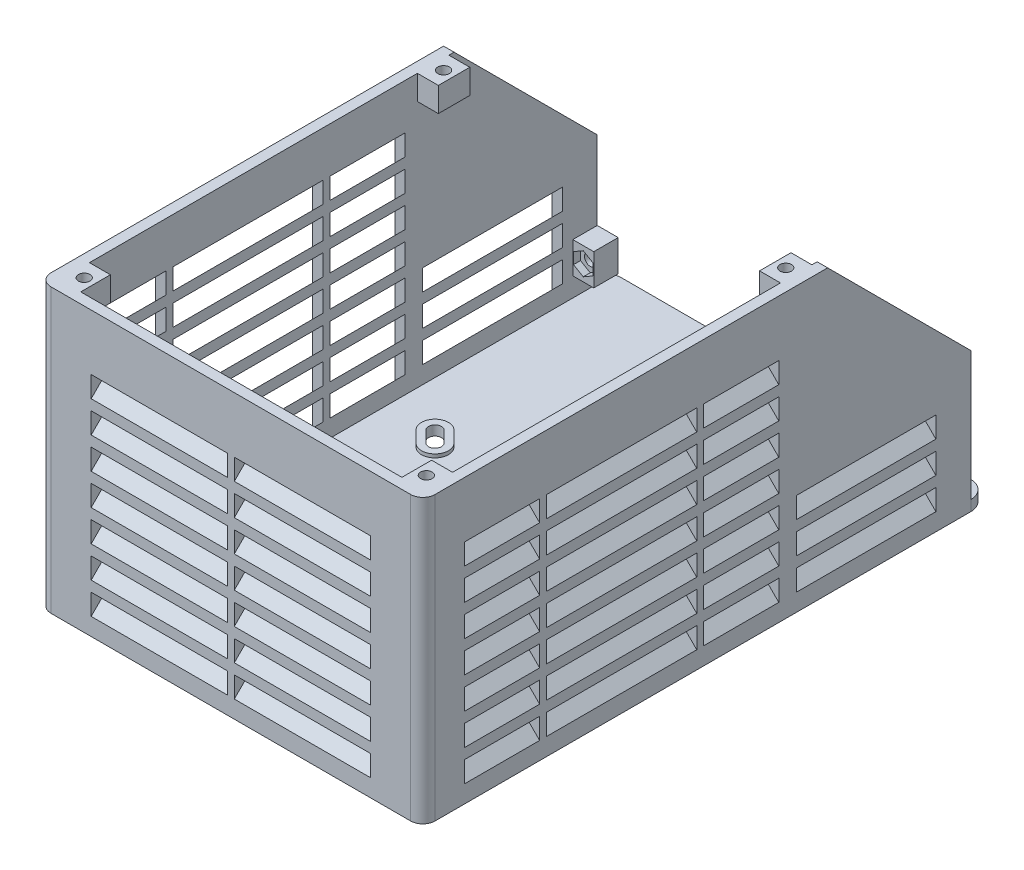
from build123d import *

# Parameters (mm, degrees)
SKETCH_2_W          = 110
SKETCH_2_H          = 161.953318806
SKETCH_2_R          = 1.75
EXTRUDE_1_DEPTH     = 3
FILLET_1_R          = 3.5
FILLET_2_R          = 5
EXTRUDE_2_DEPTH     = 78
CUT_EXTRUDE_1_DEPTH = 111
CUT_EXTRUDE_8_DEPTH = 82
CUT_EXTRUDE_9_DEPTH = 1.2
CUT_EXTRUDE_2_DEPTH = 90
CUT_EXTRUDE_3_DEPTH = 40
CUT_EXTRUDE_7_DEPTH = 40
EXTRUDE_START       = 2
SKETCH_7_W          = 3
SKETCH_7_H          = 2
SKETCH_7_W_2        = 2
SKETCH_7_H_2        = 3
EXTRUDE_3_DEPTH     = 63
EXTRUDE_7_DEPTH     = 1
SKETCH_10_R         = 5.5
CUT_EXTRUDE_4_DEPTH = 0.8
SKETCH_11_W         = 6
SKETCH_11_H         = 9
SKETCH_11_R         = 1.65
EXTRUDE_5_DEPTH     = 7
CUT_EXTRUDE_5_DEPTH = 2
SKETCH_13_W         = 6
SKETCH_13_H         = 9
SKETCH_13_R         = 1.65
EXTRUDE_6_DEPTH     = 7
CUT_EXTRUDE_6_DEPTH = 2


with BuildPart() as part:
    # 草图2 → 凸台-拉伸1 (new body)
    with BuildSketch(Plane(origin=(0, 0, 0), x_dir=(1, 0, 0), z_dir=(0, 1, 0))):
        Rectangle(SKETCH_2_W, SKETCH_2_H)
        with Locations((-37.476659403, 14.976659403)):
            Circle(SKETCH_2_R, mode=Mode.SUBTRACT)
        with Locations((-37.476659403, -59.976659403)):
            Circle(SKETCH_2_R, mode=Mode.SUBTRACT)
        with Locations((37.476659403, -59.976659403)):
            Circle(SKETCH_2_R, mode=Mode.SUBTRACT)
        with Locations((37.476659403, 14.976659403)):
            Circle(SKETCH_2_R, mode=Mode.SUBTRACT)
    extrude(amount=EXTRUDE_1_DEPTH)

    # 圆角1
    fillet_1_edges = [part.edges().sort_by_distance(p)[0] for p in [
        (55, 1.5, 80.976659403),
        (-55, 1.5, 80.976659403),
    ]]
    fillet(fillet_1_edges, radius=FILLET_1_R)

    # 圆角2
    fillet_2_edges = [part.edges().sort_by_distance(p)[0] for p in [
        (-55, 1.5, -80.976659403),
        (55, 1.5, -80.976659403),
    ]]
    fillet(fillet_2_edges, radius=FILLET_2_R)

    # 草图3 → 凸台-拉伸2 (add)
    with BuildSketch(Plane(origin=(0, 3, 0), x_dir=(1, 0, 0), z_dir=(0, 1, 0))):
        with BuildLine():
            Line((-52, 75.976659403), (-52, -77.476659403))
            ThreePointArc((-52, -77.476659403), (-51.853553391, -77.830212793), (-51.5, -77.976659403))
            Line((-51.5, -77.976659403), (51.5, -77.976659403))
            ThreePointArc((51.5, -77.976659403), (51.853553391, -77.830212793), (52, -77.476659403))
            Line((52, -77.476659403), (52, 75.976659403))
            Line((52, 75.976659403), (55, 75.976659403))
            Line((55, 75.976659403), (55, -77.476659403))
            ThreePointArc((55, -77.476659403), (53.974873734, -79.951533137), (51.5, -80.976659403))
            Line((51.5, -80.976659403), (-51.5, -80.976659403))
            ThreePointArc((-51.5, -80.976659403), (-53.974873734, -79.951533137), (-55, -77.476659403))
            Line((-55, -77.476659403), (-55, 75.976659403))
            Line((-55, 75.976659403), (-52, 75.976659403))
        make_face()
    extrude(amount=EXTRUDE_2_DEPTH)

    # 草图4 → 切除-拉伸1 (cut, through all)
    with BuildSketch(Plane(origin=(55, 0, 0), x_dir=(0, 0, -1), z_dir=(1, 0, 0))):
        Polygon((75.976659403, 81), (75.976659403, 39.987806691), (34.964466094, 81), align=None)
    extrude(amount=-CUT_EXTRUDE_1_DEPTH, mode=Mode.SUBTRACT)

    # 草图16 → 切除-拉伸8 (cut, through all)
    with BuildSketch(Plane.XZ):
        with BuildLine():
            Line((-36.663486605, 61.779781695), (-33.481506089, 58.59780118))
            ThreePointArc((-33.481506089, 58.59780118), (-33.481506089, 55.981506089), (-36.09780118, 55.981506089))
            Line((-36.09780118, 55.981506089), (-39.279781695, 59.163486605))
            ThreePointArc((-39.279781695, 59.163486605), (-39.279781695, 61.779781695), (-36.663486605, 61.779781695))
        make_face()
        with BuildLine():
            Line((39.279781695, 59.163486605), (36.09780118, 55.981506089))
            ThreePointArc((36.09780118, 55.981506089), (33.481506089, 55.981506089), (33.481506089, 58.59780118))
            Line((33.481506089, 58.59780118), (36.663486605, 61.779781695))
            ThreePointArc((36.663486605, 61.779781695), (39.279781695, 61.779781695), (39.279781695, 59.163486605))
        make_face()
        with BuildLine():
            Line((36.663486605, -16.779781695), (33.481506089, -13.59780118))
            ThreePointArc((33.481506089, -13.59780118), (33.481506089, -10.981506089), (36.09780118, -10.981506089))
            Line((36.09780118, -10.981506089), (39.279781695, -14.163486605))
            ThreePointArc((39.279781695, -14.163486605), (39.279781695, -16.779781695), (36.663486605, -16.779781695))
        make_face()
        with BuildLine():
            Line((-39.279781695, -14.163486605), (-36.09780118, -10.981506089))
            ThreePointArc((-36.09780118, -10.981506089), (-33.481506089, -10.981506089), (-33.481506089, -13.59780118))
            Line((-33.481506089, -13.59780118), (-36.663486605, -16.779781695))
            ThreePointArc((-36.663486605, -16.779781695), (-39.279781695, -16.779781695), (-39.279781695, -14.163486605))
        make_face()
    extrude(amount=-CUT_EXTRUDE_8_DEPTH, mode=Mode.SUBTRACT)

    # 草图17 → 切除-拉伸9 (cut)
    with BuildSketch(Plane.XZ):
        with BuildLine():
            Line((32.279424561, -14.799882708), (35.461405077, -17.981863223))
            ThreePointArc((35.461405077, -17.981863223), (40.481863223, -17.981863223), (40.481863223, -12.961405077))
            Line((40.481863223, -12.961405077), (37.299882708, -9.779424561))
            ThreePointArc((37.299882708, -9.779424561), (32.279424561, -9.779424561), (32.279424561, -14.799882708))
        make_face()
        with BuildLine():
            Line((33.481506089, -13.59780118), (36.663486605, -16.779781695))
            ThreePointArc((36.663486605, -16.779781695), (39.279781695, -16.779781695), (39.279781695, -14.163486605))
            Line((39.279781695, -14.163486605), (36.09780118, -10.981506089))
            ThreePointArc((36.09780118, -10.981506089), (33.481506089, -10.981506089), (33.481506089, -13.59780118))
        make_face(mode=Mode.SUBTRACT)
        with BuildLine():
            Line((-37.299882708, -9.779424561), (-40.481863223, -12.961405077))
            ThreePointArc((-40.481863223, -12.961405077), (-40.481863223, -17.981863223), (-35.461405077, -17.981863223))
            Line((-35.461405077, -17.981863223), (-32.279424561, -14.799882708))
            ThreePointArc((-32.279424561, -14.799882708), (-32.279424561, -9.779424561), (-37.299882708, -9.779424561))
        make_face()
        with BuildLine():
            Line((-36.09780118, -10.981506089), (-39.279781695, -14.163486605))
            ThreePointArc((-39.279781695, -14.163486605), (-39.279781695, -16.779781695), (-36.663486605, -16.779781695))
            Line((-36.663486605, -16.779781695), (-33.481506089, -13.59780118))
            ThreePointArc((-33.481506089, -13.59780118), (-33.481506089, -10.981506089), (-36.09780118, -10.981506089))
        make_face(mode=Mode.SUBTRACT)
        with BuildLine():
            Line((37.299882708, 54.779424561), (40.481863223, 57.961405077))
            ThreePointArc((40.481863223, 57.961405077), (40.481863223, 62.981863223), (35.461405077, 62.981863223))
            Line((35.461405077, 62.981863223), (32.279424561, 59.799882708))
            ThreePointArc((32.279424561, 59.799882708), (32.279424561, 54.779424561), (37.299882708, 54.779424561))
        make_face()
        with BuildLine():
            Line((36.09780118, 55.981506089), (39.279781695, 59.163486605))
            ThreePointArc((39.279781695, 59.163486605), (39.279781695, 61.779781695), (36.663486605, 61.779781695))
            Line((36.663486605, 61.779781695), (33.481506089, 58.59780118))
            ThreePointArc((33.481506089, 58.59780118), (33.481506089, 55.981506089), (36.09780118, 55.981506089))
        make_face(mode=Mode.SUBTRACT)
        with BuildLine():
            Line((-40.481863223, 57.961405077), (-37.299882708, 54.779424561))
            ThreePointArc((-37.299882708, 54.779424561), (-32.279424561, 54.779424561), (-32.279424561, 59.799882708))
            Line((-32.279424561, 59.799882708), (-35.461405077, 62.981863223))
            ThreePointArc((-35.461405077, 62.981863223), (-40.481863223, 62.981863223), (-40.481863223, 57.961405077))
        make_face()
        with BuildLine():
            Line((-39.279781695, 59.163486605), (-36.09780118, 55.981506089))
            ThreePointArc((-36.09780118, 55.981506089), (-33.481506089, 55.981506089), (-33.481506089, 58.59780118))
            Line((-33.481506089, 58.59780118), (-36.663486605, 61.779781695))
            ThreePointArc((-36.663486605, 61.779781695), (-39.279781695, 61.779781695), (-39.279781695, 59.163486605))
        make_face(mode=Mode.SUBTRACT)
    extrude(amount=-CUT_EXTRUDE_9_DEPTH, mode=Mode.SUBTRACT)

    # 草图6 → 切除-拉伸2 (cut)
    with BuildSketch(Plane(origin=(0, 0, -20.976659403), x_dir=(-1, 0, 0), z_dir=(0, 0, -1))):
        Polygon((-52, 68), (-55, 65), (-55, 59), (-52, 62), align=None)
        Polygon((-52, 59), (-55, 56), (-55, 50), (-52, 53), align=None)
        Polygon((-52, 50), (-55, 47), (-55, 41), (-52, 44), align=None)
        Polygon((-52, 41), (-55, 38), (-55, 32), (-52, 35), align=None)
        Polygon((-52, 32), (-55, 29), (-55, 23), (-52, 26), align=None)
        Polygon((-52, 23), (-55, 20), (-55, 14), (-52, 17), align=None)
        Polygon((-52, 14), (-55, 11), (-55, 5), (-52, 8), align=None)
        Polygon((52, 8), (55, 5), (55, 11), (52, 14), align=None)
        Polygon((52, 17), (55, 14), (55, 20), (52, 23), align=None)
        Polygon((52, 26), (55, 23), (55, 29), (52, 32), align=None)
        Polygon((52, 35), (55, 32), (55, 38), (52, 41), align=None)
        Polygon((52, 44), (55, 41), (55, 47), (52, 50), align=None)
        Polygon((52, 53), (55, 50), (55, 56), (52, 59), align=None)
        Polygon((52, 62), (55, 59), (55, 65), (52, 68), align=None)
    extrude(amount=-CUT_EXTRUDE_2_DEPTH, mode=Mode.SUBTRACT)

    # 草图8 → 切除-拉伸3 (cut, symmetric)
    with BuildSketch(Plane(origin=(0, 0, 0), x_dir=(0, 0, -1), z_dir=(1, 0, 0))):
        Polygon((-80.976659403, 65), (-77.976659403, 68), (-77.976659403, 62), (-80.976659403, 59), align=None)
        Polygon((-77.976659403, 59), (-77.976659403, 53), (-80.976659403, 50), (-80.976659403, 56), align=None)
        Polygon((-77.976659403, 50), (-77.976659403, 44), (-80.976659403, 41), (-80.976659403, 47), align=None)
        Polygon((-77.976659403, 41), (-77.976659403, 35), (-80.976659403, 32), (-80.976659403, 38), align=None)
        Polygon((-77.976659403, 32), (-77.976659403, 26), (-80.976659403, 23), (-80.976659403, 29), align=None)
        Polygon((-77.976659403, 23), (-77.976659403, 17), (-80.976659403, 14), (-80.976659403, 20), align=None)
        Polygon((-77.976659403, 14), (-77.976659403, 8), (-80.976659403, 5), (-80.976659403, 11), align=None)
    extrude(amount=CUT_EXTRUDE_3_DEPTH, both=True, mode=Mode.SUBTRACT)

    # 草图15 → 切除-拉伸7 (cut)
    with BuildSketch(Plane(origin=(0, 0, -65.976659403), x_dir=(-1, 0, 0), z_dir=(0, 0, -1))):
        Polygon((-52, 14), (-55, 11), (-55, 5), (-52, 8), align=None)
        Polygon((-55, 20), (-55, 14), (-52, 17), (-52, 23), align=None)
        Polygon((-55, 29), (-55, 23), (-52, 26), (-52, 32), align=None)
        Polygon((52, 26), (55, 23), (55, 29), (52, 32), align=None)
        Polygon((52, 17), (55, 14), (55, 20), (52, 23), align=None)
        Polygon((52, 8), (55, 5), (55, 11), (52, 14), align=None)
    extrude(amount=-CUT_EXTRUDE_7_DEPTH, mode=Mode.SUBTRACT)

    # 草图7 → 凸台-拉伸3 (add)
    with BuildSketch(Plane(origin=(0, 3, 0), x_dir=(1, 0, 0), z_dir=(0, 1, 0)).offset(EXTRUDE_START)):
        with Locations((53.5, -46.523340597)):
            Rectangle(SKETCH_7_W, SKETCH_7_H)
        with Locations((53.5, -1.523340597)):
            Rectangle(SKETCH_7_W, SKETCH_7_H)
        with Locations((-53.5, -46.523340597)):
            Rectangle(SKETCH_7_W, SKETCH_7_H)
        with Locations((-53.5, -1.523340597)):
            Rectangle(SKETCH_7_W, SKETCH_7_H)
        with Locations((0, -79.476659403)):
            Rectangle(SKETCH_7_W_2, SKETCH_7_H_2)
    extrude(amount=EXTRUDE_3_DEPTH)

    # 草图9 → 凸台-拉伸7 (add)
    with BuildSketch(Plane(origin=(0, 3, 0), x_dir=(1, 0, 0), z_dir=(0, 1, 0))):
        with BuildLine():
            Line((40.693995257, 12.749273042), (37.512014742, 9.567292527))
            ThreePointArc((37.512014742, 9.567292527), (32.067292527, 9.567292527), (32.067292527, 15.012014742))
            Line((32.067292527, 15.012014742), (35.249273042, 18.193995257))
            ThreePointArc((35.249273042, 18.193995257), (40.693995257, 18.193995257), (40.693995257, 12.749273042))
        make_face()
        with BuildLine():
            Line((39.279781695, 14.163486605), (36.09780118, 10.981506089))
            ThreePointArc((36.09780118, 10.981506089), (33.481506089, 10.981506089), (33.481506089, 13.59780118))
            Line((33.481506089, 13.59780118), (36.663486605, 16.779781695))
            ThreePointArc((36.663486605, 16.779781695), (39.279781695, 16.779781695), (39.279781695, 14.163486605))
        make_face(mode=Mode.SUBTRACT)
        with BuildLine():
            Line((-37.512014742, 9.567292527), (-40.693995257, 12.749273042))
            ThreePointArc((-40.693995257, 12.749273042), (-40.693995257, 18.193995257), (-35.249273042, 18.193995257))
            Line((-35.249273042, 18.193995257), (-32.067292527, 15.012014742))
            ThreePointArc((-32.067292527, 15.012014742), (-32.067292527, 9.567292527), (-37.512014742, 9.567292527))
        make_face()
        with BuildLine():
            Line((-36.09780118, 10.981506089), (-39.279781695, 14.163486605))
            ThreePointArc((-39.279781695, 14.163486605), (-39.279781695, 16.779781695), (-36.663486605, 16.779781695))
            Line((-36.663486605, 16.779781695), (-33.481506089, 13.59780118))
            ThreePointArc((-33.481506089, 13.59780118), (-33.481506089, 10.981506089), (-36.09780118, 10.981506089))
        make_face(mode=Mode.SUBTRACT)
        with BuildLine():
            Line((37.512014742, -54.567292527), (40.693995257, -57.749273042))
            ThreePointArc((40.693995257, -57.749273042), (40.693995257, -63.193995257), (35.249273042, -63.193995257))
            Line((35.249273042, -63.193995257), (32.067292527, -60.012014742))
            ThreePointArc((32.067292527, -60.012014742), (32.067292527, -54.567292527), (37.512014742, -54.567292527))
        make_face()
        with BuildLine():
            Line((36.09780118, -55.981506089), (39.279781695, -59.163486605))
            ThreePointArc((39.279781695, -59.163486605), (39.279781695, -61.779781695), (36.663486605, -61.779781695))
            Line((36.663486605, -61.779781695), (33.481506089, -58.59780118))
            ThreePointArc((33.481506089, -58.59780118), (33.481506089, -55.981506089), (36.09780118, -55.981506089))
        make_face(mode=Mode.SUBTRACT)
        with BuildLine():
            Line((-40.693995257, -57.749273042), (-37.512014742, -54.567292527))
            ThreePointArc((-37.512014742, -54.567292527), (-32.067292527, -54.567292527), (-32.067292527, -60.012014742))
            Line((-32.067292527, -60.012014742), (-35.249273042, -63.193995257))
            ThreePointArc((-35.249273042, -63.193995257), (-40.693995257, -63.193995257), (-40.693995257, -57.749273042))
        make_face()
        with BuildLine():
            Line((-39.279781695, -59.163486605), (-36.09780118, -55.981506089))
            ThreePointArc((-36.09780118, -55.981506089), (-33.481506089, -55.981506089), (-33.481506089, -58.59780118))
            Line((-33.481506089, -58.59780118), (-36.663486605, -61.779781695))
            ThreePointArc((-36.663486605, -61.779781695), (-39.279781695, -61.779781695), (-39.279781695, -59.163486605))
        make_face(mode=Mode.SUBTRACT)
    extrude(amount=EXTRUDE_7_DEPTH)

    # 草图10 → 切除-拉伸4 (cut)
    with BuildSketch(Plane.XZ):
        with Locations((-45, 70.976659403)):
            Circle(SKETCH_10_R)
        with Locations((45, 70.976659403)):
            Circle(SKETCH_10_R)
        with Locations((45, -70.976659403)):
            Circle(SKETCH_10_R)
        with Locations((-45, -70.976659403)):
            Circle(SKETCH_10_R)
    extrude(amount=-CUT_EXTRUDE_4_DEPTH, mode=Mode.SUBTRACT)

    # 草图11 → 凸台-拉伸5 (add)
    with BuildSketch(Plane(origin=(0, 81, 0), x_dir=(1, 0, 0), z_dir=(0, 1, 0))):
        with Locations((-49, 28.964466094)):
            Rectangle(SKETCH_11_W, SKETCH_11_H)
        with Locations((-49, 28.964466094)):
            Circle(SKETCH_11_R, mode=Mode.SUBTRACT)
        with Locations((49, 28.964466094)):
            Rectangle(SKETCH_11_W, SKETCH_11_H)
        with Locations((49, 28.964466094)):
            Circle(SKETCH_11_R, mode=Mode.SUBTRACT)
        with Locations((49, -73.976659403)):
            Rectangle(SKETCH_11_W, SKETCH_11_H)
        with Locations((49, -73.976659403)):
            Circle(SKETCH_11_R, mode=Mode.SUBTRACT)
        with Locations((-49, -73.976659403)):
            Rectangle(SKETCH_11_W, SKETCH_11_H)
        with Locations((-49, -73.976659403)):
            Circle(SKETCH_11_R, mode=Mode.SUBTRACT)
    extrude(amount=-EXTRUDE_5_DEPTH)

    # 草图12 → 切除-拉伸5 (cut)
    with BuildSketch(Plane.XZ.offset(-74)):
        Polygon((-49, -32.197627602), (-46.2, -30.581046848), (-46.2, -27.34788534), (-49, -25.731304587), (-51.8, -27.34788534), (-51.8, -30.581046848), align=None)
        Polygon((49, -32.197627602), (51.8, -30.581046848), (51.8, -27.34788534), (49, -25.731304587), (46.2, -27.34788534), (46.2, -30.581046848), align=None)
        Polygon((-49, 70.743497895), (-46.2, 72.360078649), (-46.2, 75.593240157), (-49, 77.20982091), (-51.8, 75.593240157), (-51.8, 72.360078649), align=None)
        Polygon((49, 70.743497895), (51.8, 72.360078649), (51.8, 75.593240157), (49, 77.20982091), (46.2, 75.593240157), (46.2, 72.360078649), align=None)
    extrude(amount=-CUT_EXTRUDE_5_DEPTH, mode=Mode.SUBTRACT)

    # 草图13 → 凸台-拉伸6 (add)
    with BuildSketch(Plane(origin=(0, 0, -75.976659403), x_dir=(-1, 0, 0), z_dir=(0, 0, -1))):
        with Locations((-49, 13)):
            Rectangle(SKETCH_13_W, SKETCH_13_H)
        with Locations((-49, 13)):
            Circle(SKETCH_13_R, mode=Mode.SUBTRACT)
        with Locations((49, 13)):
            Rectangle(SKETCH_13_W, SKETCH_13_H)
        with Locations((49, 13)):
            Circle(SKETCH_13_R, mode=Mode.SUBTRACT)
    extrude(amount=-EXTRUDE_6_DEPTH)

    # 草图14 → 切除-拉伸6 (cut)
    with BuildSketch(Plane.XY.offset(-68.976659403)):
        Polygon((46.2, 14.616580754), (46.2, 11.383419246), (49, 9.766838493), (51.8, 11.383419246), (51.8, 14.616580754), (49, 16.233161507), align=None)
        Polygon((-49, 16.233161507), (-51.8, 14.616580754), (-51.8, 11.383419246), (-49, 9.766838493), (-46.2, 11.383419246), (-46.2, 14.616580754), align=None)
    extrude(amount=-CUT_EXTRUDE_6_DEPTH, mode=Mode.SUBTRACT)


solid = part.part
